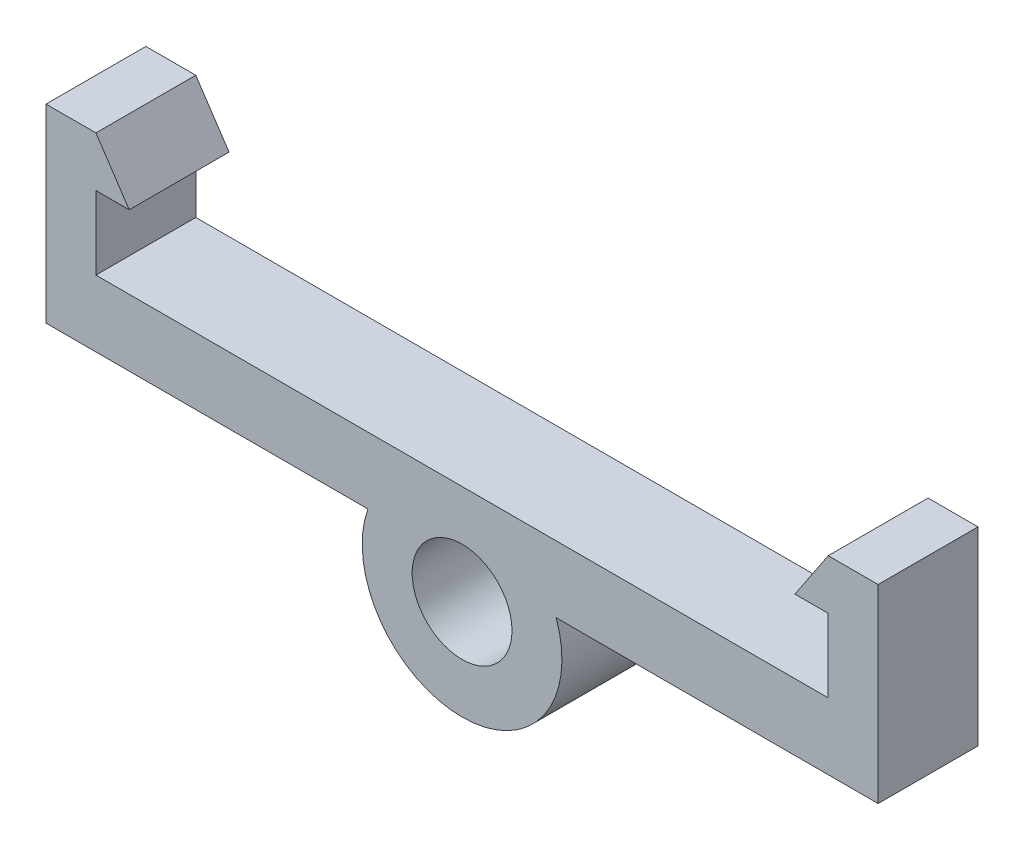
from build123d import *

# Parameters (mm, degrees)
SKIZZE1_R                       = 1.5
AUFSATZ_LINEAR_AUSTRAGEN1_DEPTH = 1.5


with BuildPart() as part:
    # Skizze1 → Aufsatz-Linear austragen1 (new body, symmetric)
    with BuildSketch(Plane.XY):
        with BuildLine():
            Line((-12.5, 5.2), (-12.5, -0.5))
            Line((-12.5, -0.5), (-2.828427125, -0.5))
            ThreePointArc((-2.828427125, -0.5), (0, -4.5), (2.828427125, -0.5))
            Line((2.828427125, -0.5), (12.5, -0.5))
            Line((12.5, -0.5), (12.5, 5.2))
            Line((12.5, 5.2), (11, 5.2))
            Line((11, 5.2), (10, 3.7))
            Line((10, 3.7), (11, 3.7))
            Line((11, 3.7), (11, 1.5))
            Line((11, 1.5), (-11, 1.5))
            Line((-11, 1.5), (-11, 3.7))
            Line((-11, 3.7), (-10, 3.7))
            Line((-10, 3.7), (-11, 5.2))
            Line((-11, 5.2), (-12.5, 5.2))
        make_face()
        with Locations((0, -1.5)):
            Circle(SKIZZE1_R, mode=Mode.SUBTRACT)
    extrude(amount=AUFSATZ_LINEAR_AUSTRAGEN1_DEPTH, both=True)


solid = part.part
